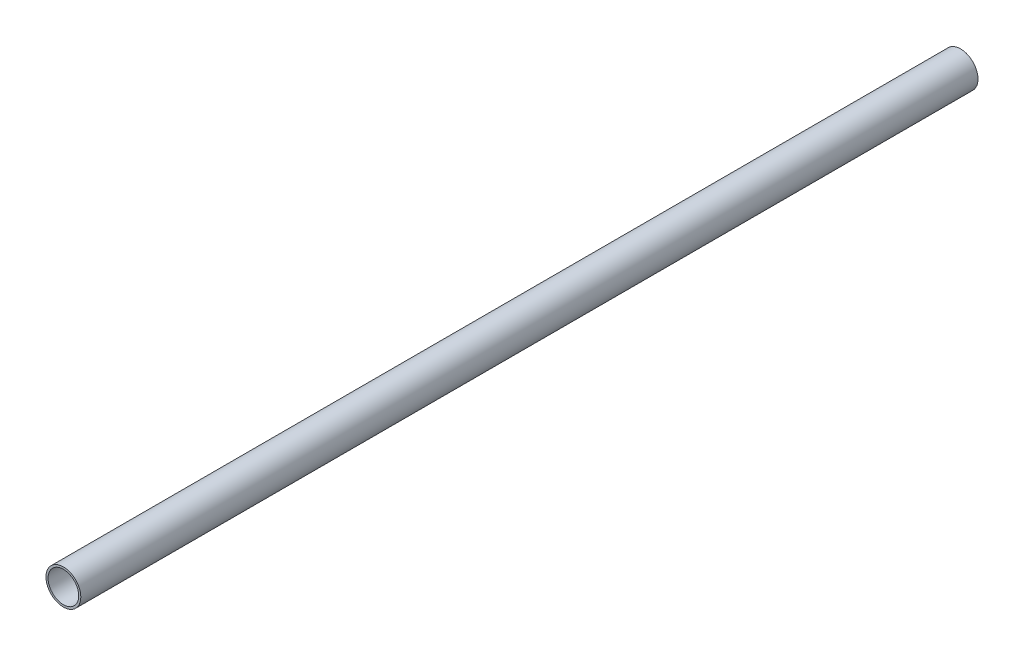
from build123d import *

# Parameters (mm, degrees)
ESQUISSE1_R        = 12.5
ESQUISSE1_R_2      = 11
BOSS_EXTRU_1_DEPTH = 644


with BuildPart() as part:
    # Esquisse1 → Boss.-Extru.1 (new body)
    with BuildSketch(Plane.XY):
        Circle(ESQUISSE1_R)
        Circle(ESQUISSE1_R_2, mode=Mode.SUBTRACT)
    extrude(amount=BOSS_EXTRU_1_DEPTH)


solid = part.part
